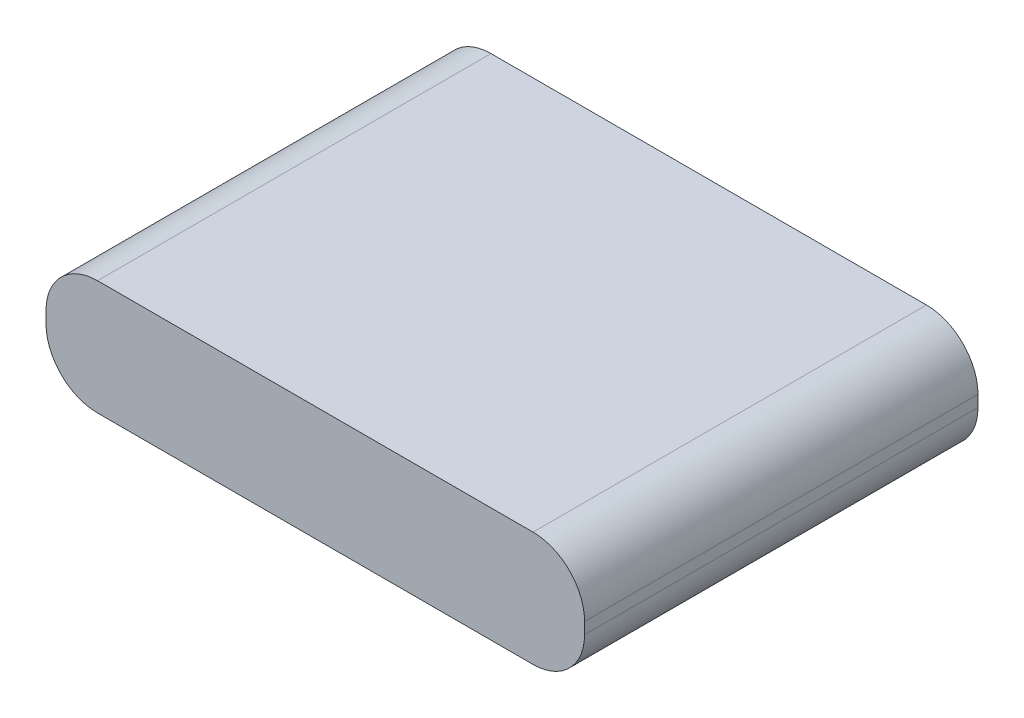
from build123d import *

# Parameters (mm, degrees)
SKETCH1_W           = 70.5
SKETCH1_H           = 51.5
BOSS_EXTRUDE1_DEPTH = 15
FILLET1_R           = 6.75


with BuildPart() as part:
    # Sketch1 → Boss-Extrude1 (new body)
    with BuildSketch(Plane(origin=(0, 0, 0), x_dir=(1, 0, 0), z_dir=(0, 1, 0))):
        Rectangle(SKETCH1_W, SKETCH1_H)
    extrude(amount=BOSS_EXTRUDE1_DEPTH)

    # Fillet1
    fillet1_edges = [part.edges().sort_by_distance(p)[0] for p in [
        (-35.25, 15, 0),
        (35.25, 15, 0),
        (-35.25, 0, 0),
        (35.25, 0, 0),
    ]]
    fillet(fillet1_edges, radius=FILLET1_R)


solid = part.part
